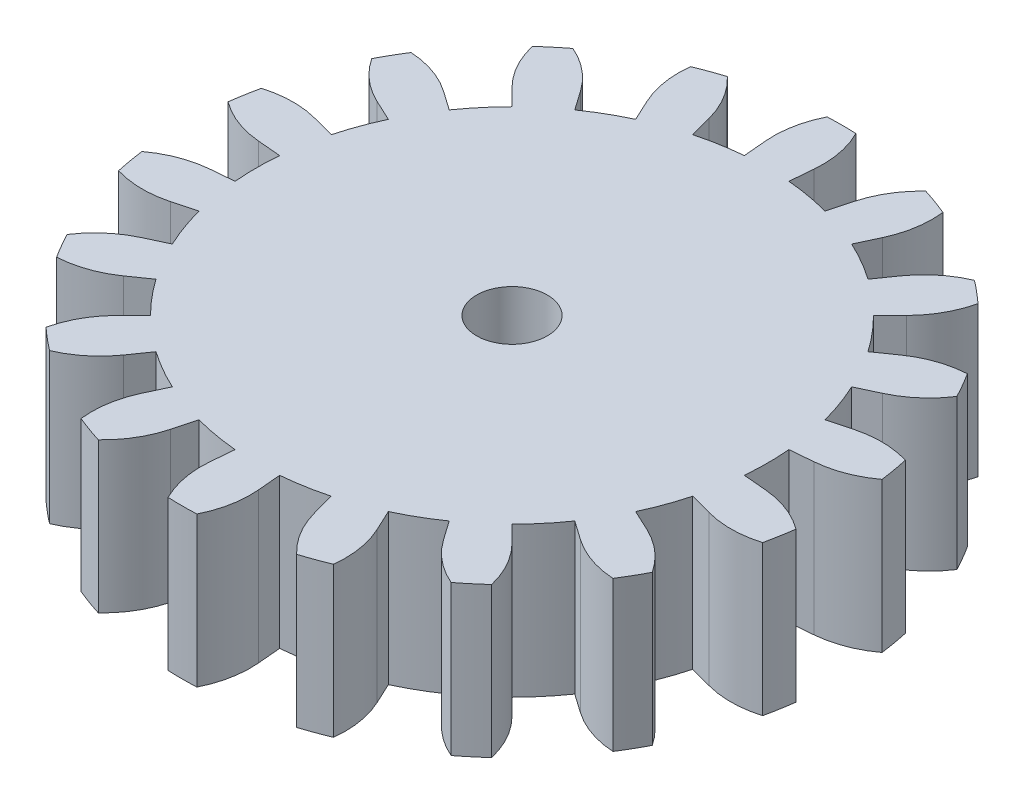
from build123d import *

# Parameters (mm, degrees)
BOSS_EXTRUDE1_DEPTH = 6.35
CIRPATTERN1_COUNT   = 18
SKETCH2_R           = 1.5
CUT_EXTRUDE1_DEPTH  = 6.35


with BuildPart() as part:
    # Sketch1 → Boss-Extrude1 (new body)
    with BuildSketch(Plane(origin=(0, 0, 0), x_dir=(1, 0, 0), z_dir=(0, 1, 0))):
        with BuildLine():
            Line((0, 0), (-1.880045408, 10.66226734))
            ThreePointArc((-1.880045408, 10.66226734), (-1.413174452, 10.734125653), (-0.943613438, 10.785550948))
            Line((-0.943613438, 10.785550948), (-1.029695335, 11.769471531))
            ThreePointArc((-1.029695335, 11.769471531), (-0.972041848, 12.892396814), (-0.609362841, 13.956703655))
            ThreePointArc((-0.609362841, 13.956703655), (0, 13.97), (0.609362841, 13.956703655))
            ThreePointArc((0.609362841, 13.956703655), (0.972041848, 12.892396814), (1.029695335, 11.769471531))
            Line((1.029695335, 11.769471531), (0.943613438, 10.785550948))
            ThreePointArc((0.943613438, 10.785550948), (1.413174452, 10.734125653), (1.880045408, 10.66226734))
            Line((1.880045408, 10.66226734), (0, 0))
        make_face()
    boss_extrude1 = extrude(amount=BOSS_EXTRUDE1_DEPTH)

    # CirPattern1: Boss-Extrude1 ×18 about axis
    cirpattern1_axis = Axis((0, 0, 0), (0, 1, 0))
    for i in range(1, CIRPATTERN1_COUNT):
        add(boss_extrude1.rotate(cirpattern1_axis, i * 360 / CIRPATTERN1_COUNT))

    # Sketch2 → Cut-Extrude1 (cut)
    with BuildSketch(Plane(origin=(0, 6.35, 0), x_dir=(1, 0, 0), z_dir=(0, 1, 0))):
        Circle(SKETCH2_R)
    extrude(amount=-CUT_EXTRUDE1_DEPTH, mode=Mode.SUBTRACT)


solid = part.part
